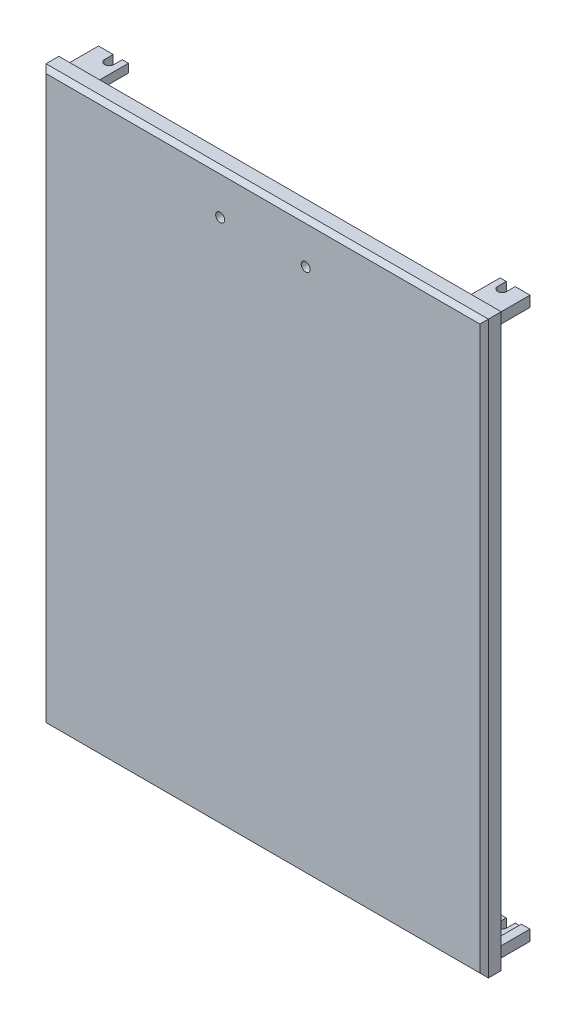
from build123d import *

# Parameters (mm, degrees)
SKETCH1_W                                = 207
SKETCH1_H                                = 267
BOSS_EXTRUDE1_DEPTH                      = 8
SKETCH2_W                                = 201.9
SKETCH2_H                                = 261.9
BOSS_EXTRUDE2_DEPTH                      = 2
BOSS_EXTRUDE3_DEPTH                      = 14
CUT_EXTRUDE1_DEPTH                       = 281.717745253
MIRROR1_AT_THE_SECOND_PLANE_COPY_1_DEPTH = 14
MIRROR1_AT_THE_SECOND_PLANE_COPY_2_DEPTH = 281.717745253
SKETCH5_R                                = 2.1
CUT_EXTRUDE2_DEPTH                       = 170.500737462
CHAMFER1_SIZE                            = 2


with BuildPart() as part:
    # Sketch1 → Boss-Extrude1 (new body)
    with BuildSketch(Plane.XY):
        Rectangle(SKETCH1_W, SKETCH1_H)
    extrude(amount=BOSS_EXTRUDE1_DEPTH)

    # Sketch2 → Boss-Extrude2 (add)
    with BuildSketch(Plane(origin=(0, 0, 0), x_dir=(-1, 0, 0), z_dir=(0, 0, -1))):
        Rectangle(SKETCH2_W, SKETCH2_H)
    extrude(amount=BOSS_EXTRUDE2_DEPTH)

    # Sketch3 → Boss-Extrude3 (add)
    with BuildSketch(Plane(origin=(0, 0, -2), x_dir=(-1, 0, 0), z_dir=(0, 0, -1))):
        Polygon((86.95, -130.95), (86.95, -126.95), (96.95, -126.95), (96.95, -125.95), (100.95, -125.95), (100.95, -130.95), align=None)
    boss_extrude3 = extrude(amount=BOSS_EXTRUDE3_DEPTH)

    # Sketch4 → Cut-Extrude1 (cut, through all)
    with BuildSketch(Plane(origin=(0, -126.95, 0), x_dir=(1, 0, 0), z_dir=(0, 1, 0))):
        with BuildLine():
            Line((-89.85, 16), (-89.85, 12))
            ThreePointArc((-89.85, 12), (-91.95, 9.9), (-94.05, 12))
            Line((-94.05, 12), (-94.05, 16))
            ThreePointArc((-94.05, 16), (-91.95, 18.1), (-89.85, 16))
        make_face()
    cut_extrude1 = extrude(amount=-CUT_EXTRUDE1_DEPTH, mode=Mode.SUBTRACT)

    # Mirror1: Boss-Extrude3, Cut-Extrude1 across plane
    add(boss_extrude3.mirror(Plane.ZX))
    add(cut_extrude1.mirror(Plane.ZX), mode=Mode.SUBTRACT)

    # Mirror1 at the second plane: Boss-Extrude3, Cut-Extrude1 across plane
    add(boss_extrude3.mirror(Plane(origin=(0, 0, 0), x_dir=(0, 0, 1), z_dir=(1, 0, 0))))
    add(cut_extrude1.mirror(Plane(origin=(0, 0, 0), x_dir=(0, 0, 1), z_dir=(1, 0, 0))), mode=Mode.SUBTRACT)

    # Mirror1 at the second plane copy 1 sketc → Mirror1 at the second plane copy 1 (add)
    with BuildSketch(Plane(origin=(0, 0, -2), x_dir=(1, 0, 0), z_dir=(0, 0, -1))):
        Polygon((86.95, -130.95), (86.95, -126.95), (96.95, -126.95), (96.95, -125.95), (100.95, -125.95), (100.95, -130.95), align=None)
    extrude(amount=MIRROR1_AT_THE_SECOND_PLANE_COPY_1_DEPTH)

    # Mirror1 at the second plane copy 2 sketc → Mirror1 at the second plane copy 2 (cut, through all)
    with BuildSketch(Plane(origin=(0, 126.95, 0), x_dir=(-1, 0, 0), z_dir=(0, -1, 0))):
        with BuildLine():
            Line((-89.85, 16), (-89.85, 12))
            ThreePointArc((-89.85, 12), (-91.95, 9.9), (-94.05, 12))
            Line((-94.05, 12), (-94.05, 16))
            ThreePointArc((-94.05, 16), (-91.95, 18.1), (-89.85, 16))
        make_face()
    extrude(amount=-MIRROR1_AT_THE_SECOND_PLANE_COPY_2_DEPTH, mode=Mode.SUBTRACT)

    # Sketch5 → Cut-Extrude2 (cut, through all)
    with BuildSketch(Plane(origin=(0, 0, -2), x_dir=(-1, 0, 0), z_dir=(0, 0, -1))):
        with Locations((-20, 113.95)):
            Circle(SKETCH5_R)
        with Locations((20, 113.95)):
            Circle(SKETCH5_R)
    extrude(amount=-CUT_EXTRUDE2_DEPTH, mode=Mode.SUBTRACT)

    # Chamfer1
    chamfer1_edges = [part.edges().sort_by_distance(p)[0] for p in [
        (-103.5, 0, 8),
        (0, -133.5, 8),
        (103.5, 0, 8),
        (0, 133.5, 8),
    ]]
    chamfer(chamfer1_edges, length=CHAMFER1_SIZE)


solid = part.part
